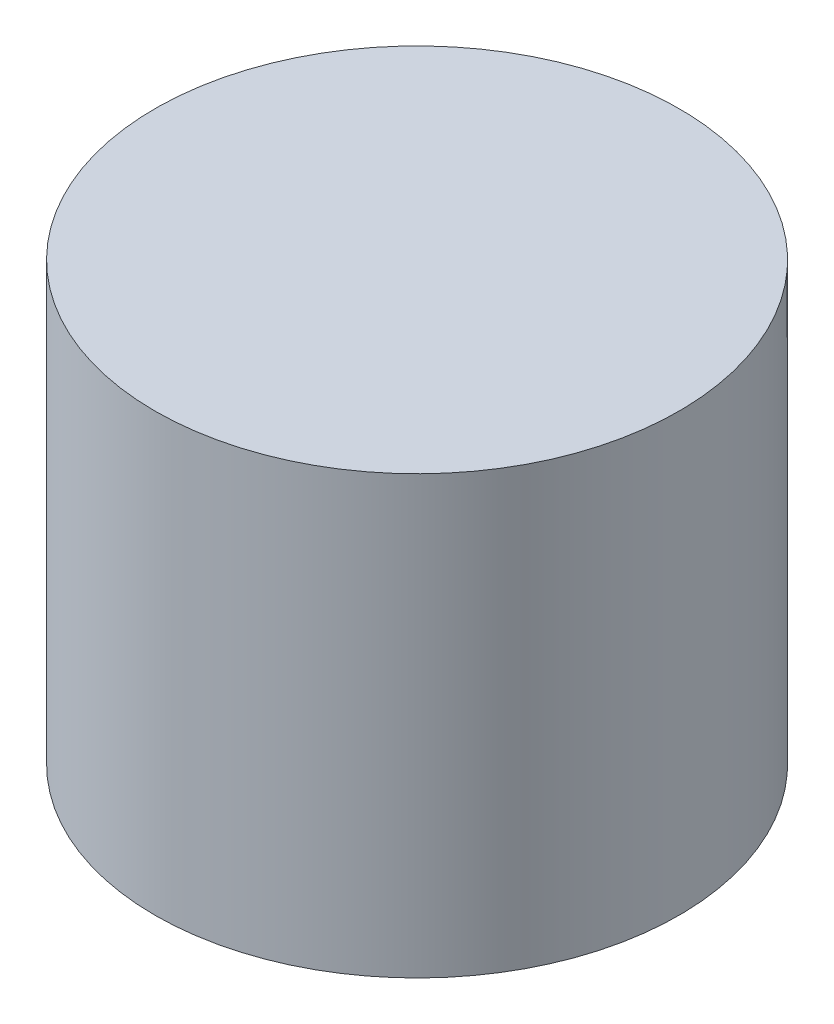
from build123d import *

# Parameters (mm, degrees)
SKETCH1_R           = 7.5
BOSS_EXTRUDE1_DEPTH = 12.5


with BuildPart() as part:
    # Sketch1 → Boss-Extrude1 (new body)
    with BuildSketch(Plane(origin=(0, 0, 0), x_dir=(1, 0, 0), z_dir=(0, 1, 0))):
        Circle(SKETCH1_R)
    extrude(amount=BOSS_EXTRUDE1_DEPTH)


solid = part.part
